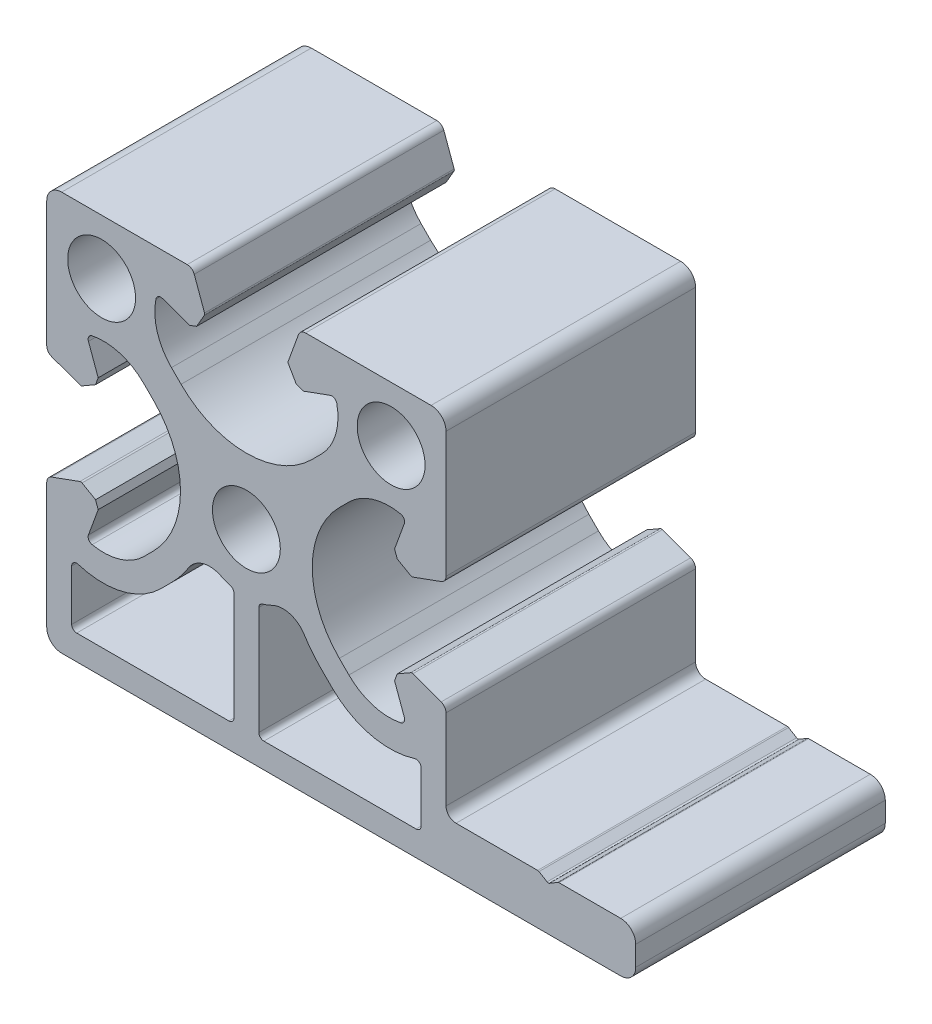
from build123d import *

# Parameters (mm, degrees)
SK_MAIN_EXTRUSION_R  = 3.4
MAIN_EXTRUSION_DEPTH = 25


with BuildPart() as part:
    # Sk Main Extrusion → Main Extrusion (new body)
    with BuildSketch(Plane.XY):
        with BuildLine():
            Line((-16.671180212, -4.190076845), (-19.506515107, -5.222054351))
            ThreePointArc((-19.506515107, -5.222054351), (-19.864364033, -5.496641489), (-20, -5.926823816))
            Line((-20, -5.926823816), (-20, -18.5))
            ThreePointArc((-20, -18.5), (-19.560660172, -19.560660172), (-18.5, -20))
            Line((-18.5, -20), (37.5, -20))
            ThreePointArc((37.5, -20), (38.560660172, -19.560660172), (39, -18.5))
            Line((39, -18.5), (39, -16.5))
            ThreePointArc((39, -16.5), (38.560660172, -15.439339828), (37.5, -15))
            Line((37.5, -15), (31.319331136, -15))
            ThreePointArc((31.319331136, -15), (31.252521542, -15.009092387), (31.190571617, -15.035708175))
            Line((31.190571617, -15.035708175), (30.378759519, -15.523494095))
            ThreePointArc((30.378759519, -15.523494095), (30.25, -15.55920227), (30.121240481, -15.523494095))
            Line((30.121240481, -15.523494095), (29.309428383, -15.035708175))
            ThreePointArc((29.309428383, -15.035708175), (29.247478458, -15.009092387), (29.180668864, -15))
            Line((29.180668864, -15), (21, -15))
            ThreePointArc((21, -15), (20.292893219, -14.707106781), (20, -14))
            Line((20, -14), (20, -5.926823816))
            ThreePointArc((20, -5.926823816), (19.864364033, -5.496641489), (19.506515107, -5.222054351))
            Line((19.506515107, -5.222054351), (16.671180212, -4.190076845))
            ThreePointArc((16.671180212, -4.190076845), (16.563886241, -4.175951325), (16.460675177, -4.208493649))
            Line((16.460675177, -4.208493649), (15.111296024, -4.987558066))
            Line((15.111296024, -4.987558066), (14.845251581, -5.718509166))
            Line((14.845251581, -5.718509166), (15.81984631, -8.396186179))
            ThreePointArc((15.81984631, -8.396186179), (15.786489799, -8.811074612), (15.450654467, -9.056960151))
            ThreePointArc((15.450654467, -9.056960151), (12.665882372, -8.933433013), (10.272684887, -7.504160339))
            Line((10.272684887, -7.504160339), (9.309262274, -6.540737726))
            ThreePointArc((9.309262274, -6.540737726), (6.6, 0), (9.309262274, 6.540737726))
            Line((9.309262274, 6.540737726), (10.272684887, 7.504160339))
            ThreePointArc((10.272684887, 7.504160339), (12.665882372, 8.933433013), (15.450654467, 9.056960151))
            ThreePointArc((15.450654467, 9.056960151), (15.786489799, 8.811074612), (15.81984631, 8.396186179))
            Line((15.81984631, 8.396186179), (14.845251581, 5.718509166))
            Line((14.845251581, 5.718509166), (15.111296024, 4.987558066))
            Line((15.111296024, 4.987558066), (16.460675177, 4.208493649))
            ThreePointArc((16.460675177, 4.208493649), (16.563886241, 4.175951325), (16.671180212, 4.190076845))
            Line((16.671180212, 4.190076845), (19.506515107, 5.222054351))
            ThreePointArc((19.506515107, 5.222054351), (19.864364033, 5.496641489), (20, 5.926823816))
            Line((20, 5.926823816), (20, 18.5))
            ThreePointArc((20, 18.5), (19.560660172, 19.560660172), (18.5, 20))
            Line((18.5, 20), (5.926823816, 20))
            ThreePointArc((5.926823816, 20), (5.496641489, 19.864364033), (5.222054351, 19.506515107))
            Line((5.222054351, 19.506515107), (4.190076845, 16.671180212))
            ThreePointArc((4.190076845, 16.671180212), (4.175951325, 16.563886241), (4.208493649, 16.460675177))
            Line((4.208493649, 16.460675177), (4.987558066, 15.111296024))
            Line((4.987558066, 15.111296024), (5.718509166, 14.845251581))
            Line((5.718509166, 14.845251581), (8.396186179, 15.81984631))
            ThreePointArc((8.396186179, 15.81984631), (8.811074612, 15.786489799), (9.056960151, 15.450654467))
            ThreePointArc((9.056960151, 15.450654467), (8.933433013, 12.665882372), (7.504160339, 10.272684887))
            Line((7.504160339, 10.272684887), (6.540737726, 9.309262274))
            ThreePointArc((6.540737726, 9.309262274), (0, 6.6), (-6.540737726, 9.309262274))
            Line((-6.540737726, 9.309262274), (-7.504160339, 10.272684887))
            ThreePointArc((-7.504160339, 10.272684887), (-8.933433013, 12.665882372), (-9.056960151, 15.450654467))
            ThreePointArc((-9.056960151, 15.450654467), (-8.811074612, 15.786489799), (-8.396186179, 15.81984631))
            Line((-8.396186179, 15.81984631), (-5.718509166, 14.845251581))
            Line((-5.718509166, 14.845251581), (-4.987558066, 15.111296024))
            Line((-4.987558066, 15.111296024), (-4.208493649, 16.460675177))
            ThreePointArc((-4.208493649, 16.460675177), (-4.175951325, 16.563886241), (-4.190076845, 16.671180212))
            Line((-4.190076845, 16.671180212), (-5.222054351, 19.506515107))
            ThreePointArc((-5.222054351, 19.506515107), (-5.496641489, 19.864364033), (-5.926823816, 20))
            Line((-5.926823816, 20), (-18.5, 20))
            ThreePointArc((-18.5, 20), (-19.560660172, 19.560660172), (-20, 18.5))
            Line((-20, 18.5), (-20, 5.926823816))
            ThreePointArc((-20, 5.926823816), (-19.864364033, 5.496641489), (-19.506515107, 5.222054351))
            Line((-19.506515107, 5.222054351), (-16.671180212, 4.190076845))
            ThreePointArc((-16.671180212, 4.190076845), (-16.563886241, 4.175951325), (-16.460675177, 4.208493649))
            Line((-16.460675177, 4.208493649), (-15.111296024, 4.987558066))
            Line((-15.111296024, 4.987558066), (-14.845251581, 5.718509166))
            Line((-14.845251581, 5.718509166), (-15.81984631, 8.396186179))
            ThreePointArc((-15.81984631, 8.396186179), (-15.786489799, 8.811074612), (-15.450654467, 9.056960151))
            ThreePointArc((-15.450654467, 9.056960151), (-12.665882372, 8.933433013), (-10.272684887, 7.504160339))
            Line((-10.272684887, 7.504160339), (-9.309262274, 6.540737726))
            ThreePointArc((-9.309262274, 6.540737726), (-6.6, 0), (-9.309262274, -6.540737726))
            Line((-9.309262274, -6.540737726), (-10.272684887, -7.504160339))
            ThreePointArc((-10.272684887, -7.504160339), (-12.665882372, -8.933433013), (-15.450654467, -9.056960151))
            ThreePointArc((-15.450654467, -9.056960151), (-15.786489799, -8.811074612), (-15.81984631, -8.396186179))
            Line((-15.81984631, -8.396186179), (-14.845251581, -5.718509166))
            Line((-14.845251581, -5.718509166), (-15.111296024, -4.987558066))
            Line((-15.111296024, -4.987558066), (-16.460675177, -4.208493649))
            ThreePointArc((-16.460675177, -4.208493649), (-16.563886241, -4.175951325), (-16.671180212, -4.190076845))
        make_face()
        with Locations((14.5, 14.5)):
            Circle(SK_MAIN_EXTRUSION_R, mode=Mode.SUBTRACT)
        Circle(SK_MAIN_EXTRUSION_R, mode=Mode.SUBTRACT)
        with Locations((-14.5, 14.5)):
            Circle(SK_MAIN_EXTRUSION_R, mode=Mode.SUBTRACT)
        with BuildLine():
            Line((-7.441495321, -8.308504679), (-8.577273231, -9.444282589))
            ThreePointArc((-8.577273231, -9.444282589), (-12.430514315, -11.611987193), (-16.849169473, -11.464011904))
            ThreePointArc((-16.849169473, -11.464011904), (-17.295452819, -11.537349181), (-17.5, -11.940719521))
            Line((-17.5, -11.940719521), (-17.5, -17))
            ThreePointArc((-17.5, -17), (-17.353553391, -17.353553391), (-17, -17.5))
            Line((-17, -17.5), (-1.75, -17.5))
            ThreePointArc((-1.75, -17.5), (-1.396446609, -17.353553391), (-1.25, -17))
            Line((-1.25, -17), (-1.25, -6.156094541))
            ThreePointArc((-1.25, -6.156094541), (-1.351026708, -5.854730455), (-1.61328125, -5.675149655))
            ThreePointArc((-1.61328125, -5.675149655), (-2.10305366, -5.51245547), (-2.576734694, -5.307583096))
            ThreePointArc((-2.576734694, -5.307583096), (-4.359333373, -5.153883821), (-5.788120301, -6.230846881))
            ThreePointArc((-5.788120301, -6.230846881), (-6.555931161, -7.316529108), (-7.441495321, -8.308504679))
        make_face(mode=Mode.SUBTRACT)
        with BuildLine():
            Line((1.25, -6.156094541), (1.25, -17))
            ThreePointArc((1.25, -17), (1.396446609, -17.353553391), (1.75, -17.5))
            Line((1.75, -17.5), (17, -17.5))
            ThreePointArc((17, -17.5), (17.353553391, -17.353553391), (17.5, -17))
            Line((17.5, -17), (17.5, -11.940719521))
            ThreePointArc((17.5, -11.940719521), (17.295452819, -11.537349181), (16.849169473, -11.464011904))
            ThreePointArc((16.849169473, -11.464011904), (12.430514315, -11.611987193), (8.577273231, -9.444282589))
            Line((8.577273231, -9.444282589), (7.441495321, -8.308504679))
            ThreePointArc((7.441495321, -8.308504679), (6.555931161, -7.316529108), (5.788120301, -6.230846881))
            ThreePointArc((5.788120301, -6.230846881), (4.359333373, -5.153883821), (2.576734694, -5.307583096))
            ThreePointArc((2.576734694, -5.307583096), (2.10305366, -5.51245547), (1.61328125, -5.675149655))
            ThreePointArc((1.61328125, -5.675149655), (1.351026708, -5.854730455), (1.25, -6.156094541))
        make_face(mode=Mode.SUBTRACT)
    extrude(amount=-MAIN_EXTRUSION_DEPTH)


solid = part.part
